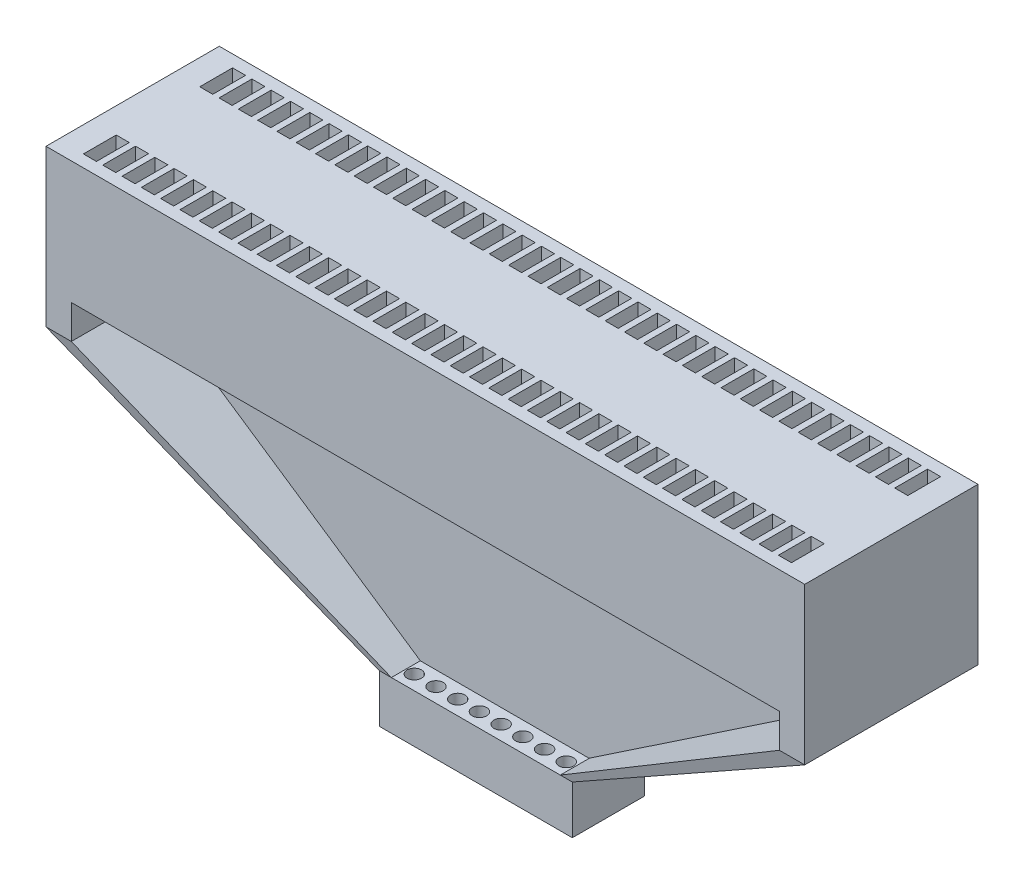
from build123d import *

# Parameters (mm, degrees)
MAIN_BLOCK_W             = 15.72
MAIN_BLOCK_H             = 3.59
MAIN_WELL_BLOCK_DEPTH    = 2.54
WELL_SKETCH_W            = 0.27
WELL_SKETCH_H            = 0.68
WELLS_DEPTH              = 2.54
SUPPORT_BEAMS_W          = 0.525137189
SUPPORT_BEAMS_H          = 3.59
SUPPORT_BEAMS_W_2        = 0.5251
SUPPORT_BEAMS_EXTR_DEPTH = 0.7
SKETCH6_W                = 0.25
SKETCH6_H                = 1.5
SKETCH7_W                = 0.25
SKETCH7_H                = 1.5
WALL_DIVIDER_SKETCH_W    = 14.669725622
WALL_DIVIDER_SKETCH_H    = 0.3
BOSS_EXTRUDE3_DEPTH      = 0.7
SKETCH8_W                = 3.493850966
SKETCH8_H                = 0.3
EXIT_BASE_SKETCH_W       = 4
EXIT_BASE_SKETCH_H       = 1.5
EXIT_BASE_SKETCH_R       = 0.15
BOSS_EXTRUDE4_DEPTH      = 1


with BuildPart() as part:
    # main block → Main Well Block (new body)
    with BuildSketch(Plane(origin=(0, 0, 0), x_dir=(1, 0, 0), z_dir=(0, 1, 0))):
        Rectangle(MAIN_BLOCK_W, MAIN_BLOCK_H)
    extrude(amount=-MAIN_WELL_BLOCK_DEPTH)

    # well sketch → wells (cut)
    with BuildSketch(Plane(origin=(0, 0, 0), x_dir=(1, 0, 0), z_dir=(0, 1, 0))):
        with Locations((7.1999, 1.205)):
            Rectangle(WELL_SKETCH_W, WELL_SKETCH_H)
        with Locations((6.799906589, 1.205)):
            Rectangle(WELL_SKETCH_W, WELL_SKETCH_H)
        with Locations((6.399913177, 1.205)):
            Rectangle(WELL_SKETCH_W, WELL_SKETCH_H)
        with Locations((5.999919766, 1.205)):
            Rectangle(WELL_SKETCH_W, WELL_SKETCH_H)
        with Locations((5.599926354, 1.205)):
            Rectangle(WELL_SKETCH_W, WELL_SKETCH_H)
        with Locations((5.199932943, 1.205)):
            Rectangle(WELL_SKETCH_W, WELL_SKETCH_H)
        with Locations((4.799939532, 1.205)):
            Rectangle(WELL_SKETCH_W, WELL_SKETCH_H)
        with Locations((4.39994612, 1.205)):
            Rectangle(WELL_SKETCH_W, WELL_SKETCH_H)
        with Locations((3.999952709, 1.205)):
            Rectangle(WELL_SKETCH_W, WELL_SKETCH_H)
        with Locations((3.599959297, 1.205)):
            Rectangle(WELL_SKETCH_W, WELL_SKETCH_H)
        with Locations((3.199965886, 1.205)):
            Rectangle(WELL_SKETCH_W, WELL_SKETCH_H)
        with Locations((2.799972474, 1.205)):
            Rectangle(WELL_SKETCH_W, WELL_SKETCH_H)
        with Locations((2.399979063, 1.205)):
            Rectangle(WELL_SKETCH_W, WELL_SKETCH_H)
        with Locations((1.999985652, 1.205)):
            Rectangle(WELL_SKETCH_W, WELL_SKETCH_H)
        with Locations((1.59999224, 1.205)):
            Rectangle(WELL_SKETCH_W, WELL_SKETCH_H)
        with Locations((1.199998829, 1.205)):
            Rectangle(WELL_SKETCH_W, WELL_SKETCH_H)
        with Locations((0.800005417, 1.205)):
            Rectangle(WELL_SKETCH_W, WELL_SKETCH_H)
        with Locations((0.400012006, 1.205)):
            Rectangle(WELL_SKETCH_W, WELL_SKETCH_H)
        with Locations((1.8595e-05, 1.205)):
            Rectangle(WELL_SKETCH_W, WELL_SKETCH_H)
        with Locations((-0.399974817, 1.205)):
            Rectangle(WELL_SKETCH_W, WELL_SKETCH_H)
        with Locations((-0.799968228, 1.205)):
            Rectangle(WELL_SKETCH_W, WELL_SKETCH_H)
        with Locations((-1.19996164, 1.205)):
            Rectangle(WELL_SKETCH_W, WELL_SKETCH_H)
        with Locations((-1.599955051, 1.205)):
            Rectangle(WELL_SKETCH_W, WELL_SKETCH_H)
        with Locations((-1.999948462, 1.205)):
            Rectangle(WELL_SKETCH_W, WELL_SKETCH_H)
        with Locations((-2.399941874, 1.205)):
            Rectangle(WELL_SKETCH_W, WELL_SKETCH_H)
        with Locations((-2.799935285, 1.205)):
            Rectangle(WELL_SKETCH_W, WELL_SKETCH_H)
        with Locations((-3.199928697, 1.205)):
            Rectangle(WELL_SKETCH_W, WELL_SKETCH_H)
        with Locations((-3.599922108, 1.205)):
            Rectangle(WELL_SKETCH_W, WELL_SKETCH_H)
        with Locations((-3.99991552, 1.205)):
            Rectangle(WELL_SKETCH_W, WELL_SKETCH_H)
        with Locations((-4.399908931, 1.205)):
            Rectangle(WELL_SKETCH_W, WELL_SKETCH_H)
        with Locations((-4.799902342, 1.205)):
            Rectangle(WELL_SKETCH_W, WELL_SKETCH_H)
        with Locations((-5.199895754, 1.205)):
            Rectangle(WELL_SKETCH_W, WELL_SKETCH_H)
        with Locations((-5.599889165, 1.205)):
            Rectangle(WELL_SKETCH_W, WELL_SKETCH_H)
        with Locations((-5.999882577, 1.205)):
            Rectangle(WELL_SKETCH_W, WELL_SKETCH_H)
        with Locations((-6.399875988, 1.205)):
            Rectangle(WELL_SKETCH_W, WELL_SKETCH_H)
        with Locations((6.799906589, -1.205)):
            Rectangle(WELL_SKETCH_W, WELL_SKETCH_H)
        with Locations((6.399913177, -1.205)):
            Rectangle(WELL_SKETCH_W, WELL_SKETCH_H)
        with Locations((5.999919766, -1.205)):
            Rectangle(WELL_SKETCH_W, WELL_SKETCH_H)
        with Locations((5.599926354, -1.205)):
            Rectangle(WELL_SKETCH_W, WELL_SKETCH_H)
        with Locations((5.199932943, -1.205)):
            Rectangle(WELL_SKETCH_W, WELL_SKETCH_H)
        with Locations((4.799939532, -1.205)):
            Rectangle(WELL_SKETCH_W, WELL_SKETCH_H)
        with Locations((4.39994612, -1.205)):
            Rectangle(WELL_SKETCH_W, WELL_SKETCH_H)
        with Locations((3.999952709, -1.205)):
            Rectangle(WELL_SKETCH_W, WELL_SKETCH_H)
        with Locations((3.599959297, -1.205)):
            Rectangle(WELL_SKETCH_W, WELL_SKETCH_H)
        with Locations((3.199965886, -1.205)):
            Rectangle(WELL_SKETCH_W, WELL_SKETCH_H)
        with Locations((2.799972474, -1.205)):
            Rectangle(WELL_SKETCH_W, WELL_SKETCH_H)
        with Locations((2.399979063, -1.205)):
            Rectangle(WELL_SKETCH_W, WELL_SKETCH_H)
        with Locations((1.999985652, -1.205)):
            Rectangle(WELL_SKETCH_W, WELL_SKETCH_H)
        with Locations((1.59999224, -1.205)):
            Rectangle(WELL_SKETCH_W, WELL_SKETCH_H)
        with Locations((1.199998829, -1.205)):
            Rectangle(WELL_SKETCH_W, WELL_SKETCH_H)
        with Locations((0.800005417, -1.205)):
            Rectangle(WELL_SKETCH_W, WELL_SKETCH_H)
        with Locations((0.400012006, -1.205)):
            Rectangle(WELL_SKETCH_W, WELL_SKETCH_H)
        with Locations((1.8595e-05, -1.205)):
            Rectangle(WELL_SKETCH_W, WELL_SKETCH_H)
        with Locations((-0.399974817, -1.205)):
            Rectangle(WELL_SKETCH_W, WELL_SKETCH_H)
        with Locations((-0.799968228, -1.205)):
            Rectangle(WELL_SKETCH_W, WELL_SKETCH_H)
        with Locations((-1.19996164, -1.205)):
            Rectangle(WELL_SKETCH_W, WELL_SKETCH_H)
        with Locations((-1.599955051, -1.205)):
            Rectangle(WELL_SKETCH_W, WELL_SKETCH_H)
        with Locations((-1.999948462, -1.205)):
            Rectangle(WELL_SKETCH_W, WELL_SKETCH_H)
        with Locations((-2.399941874, -1.205)):
            Rectangle(WELL_SKETCH_W, WELL_SKETCH_H)
        with Locations((-2.799935285, -1.205)):
            Rectangle(WELL_SKETCH_W, WELL_SKETCH_H)
        with Locations((-3.199928697, -1.205)):
            Rectangle(WELL_SKETCH_W, WELL_SKETCH_H)
        with Locations((-3.599922108, -1.205)):
            Rectangle(WELL_SKETCH_W, WELL_SKETCH_H)
        with Locations((-3.99991552, -1.205)):
            Rectangle(WELL_SKETCH_W, WELL_SKETCH_H)
        with Locations((-4.399908931, -1.205)):
            Rectangle(WELL_SKETCH_W, WELL_SKETCH_H)
        with Locations((-4.799902342, -1.205)):
            Rectangle(WELL_SKETCH_W, WELL_SKETCH_H)
        with Locations((-5.199895754, -1.205)):
            Rectangle(WELL_SKETCH_W, WELL_SKETCH_H)
        with Locations((-5.599889165, -1.205)):
            Rectangle(WELL_SKETCH_W, WELL_SKETCH_H)
        with Locations((-5.999882577, -1.205)):
            Rectangle(WELL_SKETCH_W, WELL_SKETCH_H)
        with Locations((-6.399875988, -1.205)):
            Rectangle(WELL_SKETCH_W, WELL_SKETCH_H)
        with Locations((7.1999, -1.205)):
            Rectangle(WELL_SKETCH_W, WELL_SKETCH_H)
        with Locations((-6.799869399, 1.205)):
            Rectangle(WELL_SKETCH_W, WELL_SKETCH_H)
        with Locations((-7.199862811, 1.205)):
            Rectangle(WELL_SKETCH_W, WELL_SKETCH_H)
        with Locations((-6.799869399, -1.205)):
            Rectangle(WELL_SKETCH_W, WELL_SKETCH_H)
        with Locations((-7.199862811, -1.205)):
            Rectangle(WELL_SKETCH_W, WELL_SKETCH_H)
    extrude(amount=-WELLS_DEPTH, mode=Mode.SUBTRACT)

    # support beams → support beams extr (add)
    with BuildSketch(Plane.XZ.offset(2.54)):
        with Locations((-7.597431406, 0)):
            Rectangle(SUPPORT_BEAMS_W, SUPPORT_BEAMS_H)
        with Locations((7.59745, 0)):
            Rectangle(SUPPORT_BEAMS_W_2, SUPPORT_BEAMS_H)
    extrude(amount=SUPPORT_BEAMS_EXTR_DEPTH)

    # Sketch6 → section 0 of arm1
    with BuildSketch(Plane(origin=(0, -7, 0), x_dir=(1, 0, 0), z_dir=(0, 1, 0)), mode=Mode.PRIVATE) as arm1_s0:
        with Locations((-1.875, 0)):
            Rectangle(SKETCH6_W, SKETCH6_H)
    # loft up to a face of the part (arm1)
    loft([arm1_s0.sketch, part.faces().sort_by_distance((-7.597431405, -3.24, 0))[0]])

    # Sketch7 → section 0 of arm2
    with BuildSketch(Plane(origin=(0, -7, 0), x_dir=(1, 0, 0), z_dir=(0, 1, 0)), mode=Mode.PRIVATE) as arm2_s0:
        with Locations((1.875, 0)):
            Rectangle(SKETCH7_W, SKETCH7_H)
    # loft up to a face of the part (arm2)
    loft([arm2_s0.sketch, part.faces().sort_by_distance((7.59745, -3.24, 0))[0]])

    # wall divider sketch → Boss-Extrude3 (add)
    with BuildSketch(Plane(origin=(0, -2.54, 0), x_dir=(-1, 0, 0), z_dir=(0, -1, 0))):
        Rectangle(WALL_DIVIDER_SKETCH_W, WALL_DIVIDER_SKETCH_H)
    extrude(amount=BOSS_EXTRUDE3_DEPTH)

    # Sketch8 → section 1 of divider_wall
    with BuildSketch(Plane(origin=(0, -7, 0), x_dir=(1, 0, 0), z_dir=(0, 1, 0)), mode=Mode.PRIVATE) as divider_wall_s1:
        Rectangle(SKETCH8_W, SKETCH8_H)
    # loft from a face of the part (divider_wall)
    loft([part.faces().sort_by_distance((0, -3.24, 0))[0], divider_wall_s1.sketch])


with BuildPart() as body_2:
    # exit base sketch → Boss-Extrude4 (new body)
    with BuildSketch(Plane(origin=(0, -7, 0), x_dir=(1, 0, 0), z_dir=(0, 1, 0))):
        Rectangle(EXIT_BASE_SKETCH_W, EXIT_BASE_SKETCH_H)
        with Locations((1.575, -0.45)):
            Circle(EXIT_BASE_SKETCH_R, mode=Mode.SUBTRACT)
        with Locations((1.125, -0.45)):
            Circle(EXIT_BASE_SKETCH_R, mode=Mode.SUBTRACT)
        with Locations((0.675, -0.45)):
            Circle(EXIT_BASE_SKETCH_R, mode=Mode.SUBTRACT)
        with Locations((0.225, -0.45)):
            Circle(EXIT_BASE_SKETCH_R, mode=Mode.SUBTRACT)
        with Locations((-0.225, -0.45)):
            Circle(EXIT_BASE_SKETCH_R, mode=Mode.SUBTRACT)
        with Locations((-0.675, -0.45)):
            Circle(EXIT_BASE_SKETCH_R, mode=Mode.SUBTRACT)
        with Locations((-1.125, -0.45)):
            Circle(EXIT_BASE_SKETCH_R, mode=Mode.SUBTRACT)
        with Locations((-1.575, -0.45)):
            Circle(EXIT_BASE_SKETCH_R, mode=Mode.SUBTRACT)
        with Locations((1.125, 0.45)):
            Circle(EXIT_BASE_SKETCH_R, mode=Mode.SUBTRACT)
        with Locations((0.675, 0.45)):
            Circle(EXIT_BASE_SKETCH_R, mode=Mode.SUBTRACT)
        with Locations((0.225, 0.45)):
            Circle(EXIT_BASE_SKETCH_R, mode=Mode.SUBTRACT)
        with Locations((-0.225, 0.45)):
            Circle(EXIT_BASE_SKETCH_R, mode=Mode.SUBTRACT)
        with Locations((-0.675, 0.45)):
            Circle(EXIT_BASE_SKETCH_R, mode=Mode.SUBTRACT)
        with Locations((-1.125, 0.45)):
            Circle(EXIT_BASE_SKETCH_R, mode=Mode.SUBTRACT)
        with Locations((-1.575, 0.45)):
            Circle(EXIT_BASE_SKETCH_R, mode=Mode.SUBTRACT)
        with Locations((1.575, 0.45)):
            Circle(EXIT_BASE_SKETCH_R, mode=Mode.SUBTRACT)
    extrude(amount=-BOSS_EXTRUDE4_DEPTH)


solid = Compound([part.part, body_2.part])
